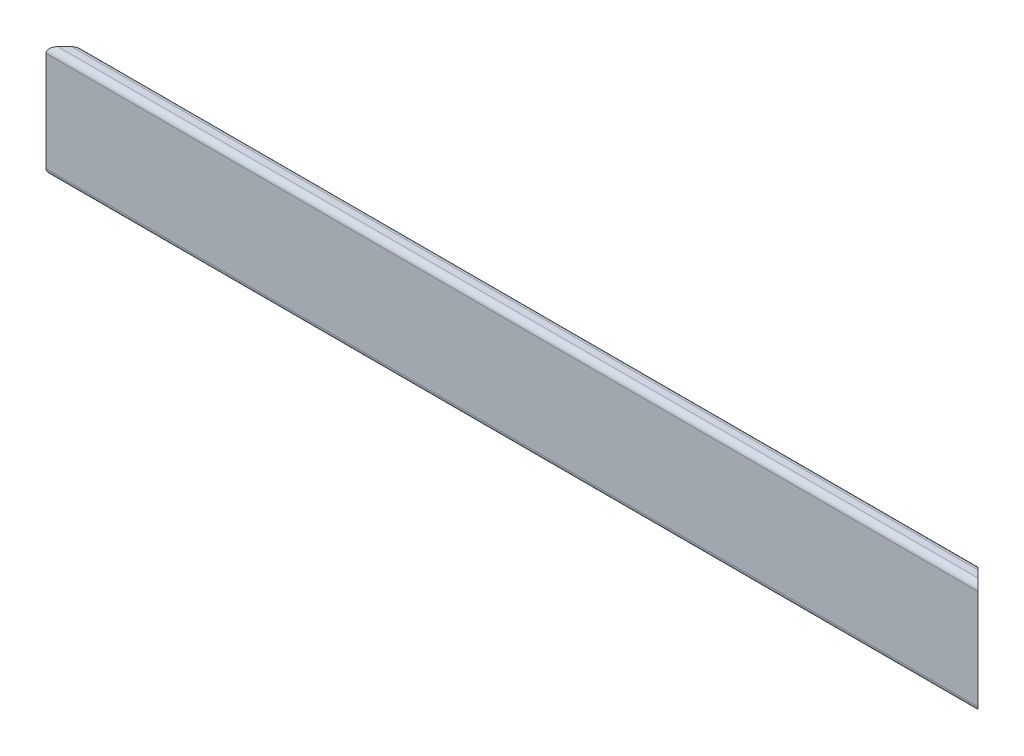
from build123d import *

# Parameters (mm, degrees)
BOSS_EXTRUDE1_DEPTH = 19.05
FILLET1_R           = 2


with BuildPart() as part:
    # Sketch1 → Boss-Extrude1 (new body, symmetric)
    with BuildSketch(Plane(origin=(0, 0, 0), x_dir=(1, 0, 0), z_dir=(0, 1, 0))):
        Polygon((-153, 0), (153, 0), (159.35, -6.35), (-159.35, -6.35), align=None)
    extrude(amount=BOSS_EXTRUDE1_DEPTH, both=True)

    # Fillet1
    fillet1_edges = [part.edges().sort_by_distance(p)[0] for p in [
        (0, 19.05, 0),
        (0, -19.05, 6.35),
        (0, 19.05, 6.35),
    ]]
    fillet(fillet1_edges, radius=FILLET1_R)


solid = part.part
